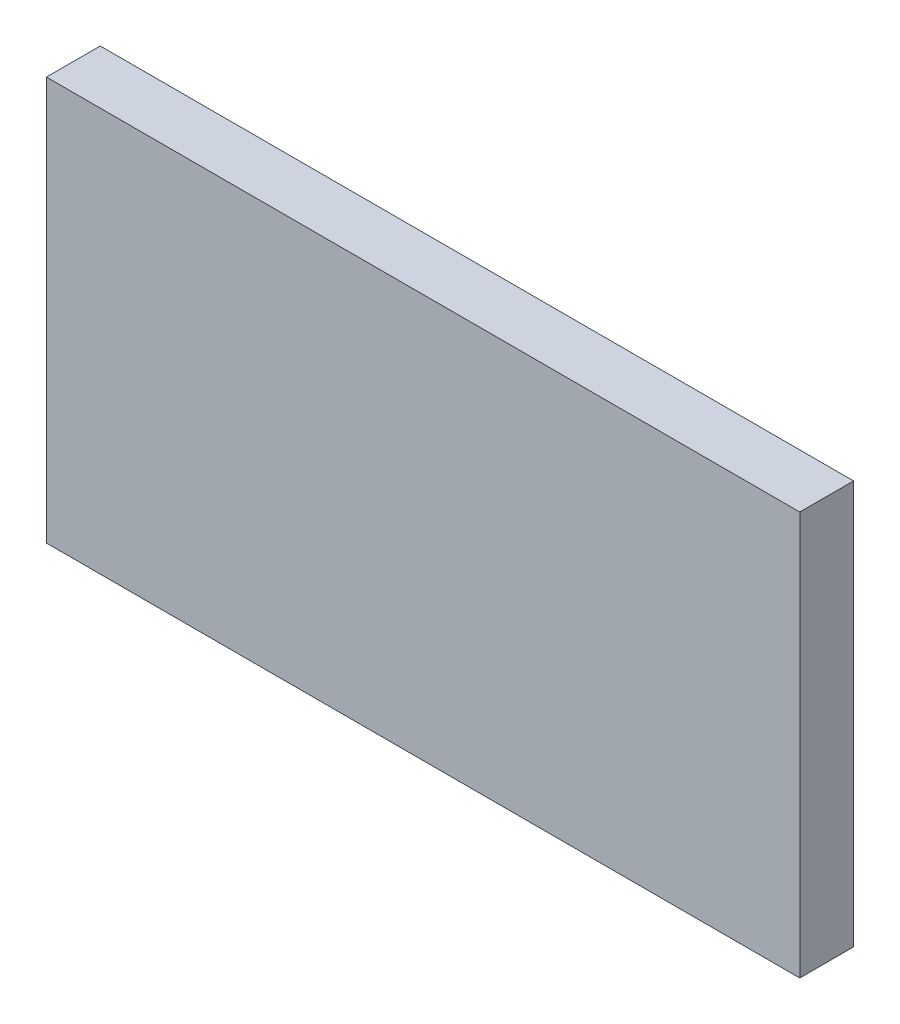
from build123d import *

# Parameters (mm, degrees)
CROQUIS1_W              = 280
CROQUIS1_H              = 150
SALIENTE_EXTRUIR1_DEPTH = 20


with BuildPart() as part:
    # Croquis1 → Saliente-Extruir1 (new body)
    with BuildSketch(Plane.XY):
        with Locations((-26.58436214, 14.74789916)):
            Rectangle(CROQUIS1_W, CROQUIS1_H)
    extrude(amount=SALIENTE_EXTRUIR1_DEPTH)


solid = part.part
